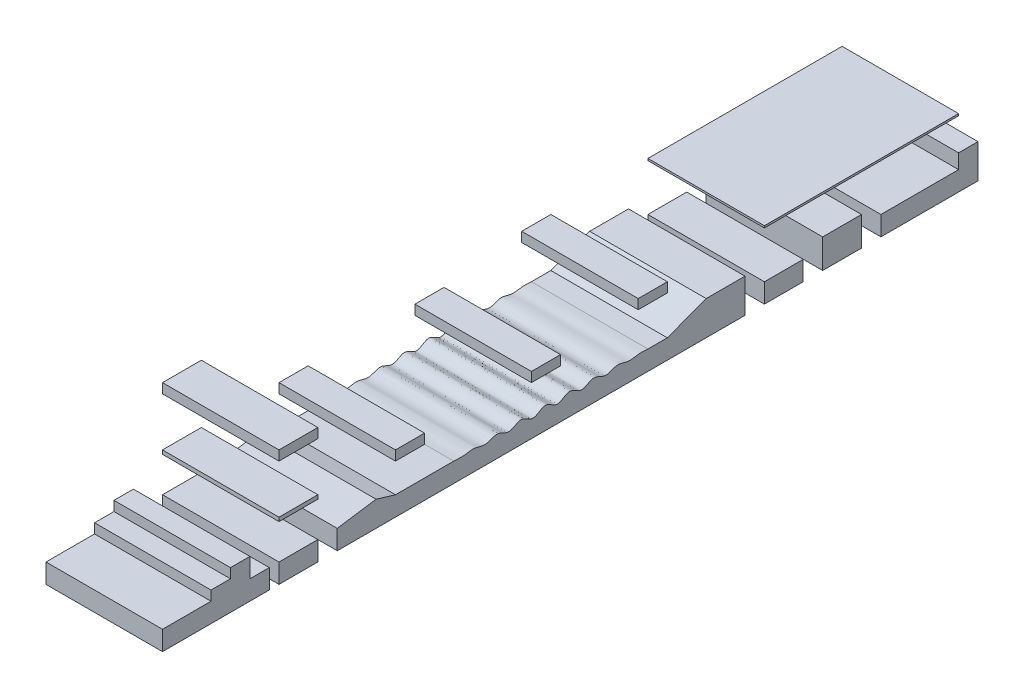
from build123d import *

# Parameters (mm, degrees)
EXTRUDE_1_DEPTH             = 3
EXTRUDE_1_2_DEPTH           = 3
SKETCH_1_W                  = 10
SKETCH_1_H                  = 0.1
EXTRUDE_1_3_DEPTH           = 3
SKETCH_1_W_2                = 2
SKETCH_1_H_2                = 1.5
EXTRUDE_1_4_DEPTH           = 3
SKETCH_1_H_3                = 1
EXTRUDE_1_5_DEPTH           = 3
SKETCH_1_W_3                = 15
EXTRUDE_1_6_DEPTH           = 3
EXTRUDE_2_DEPTH             = 3
EXTRUDE_2_DEPTH_BACK        = 3
EXTRUDE_3_DEPTH             = 3
EXTRUDE_3_DEPTH_BACK        = 3
CUT_EXTRUDE_START           = 3
SKETCH_4_W                  = 0.5
SKETCH_4_H                  = 1
SKETCH_4_W_2                = 1
CUT_EXTRUDE_1_DEPTH         = 7.0000001
EXTRUDE_4_REACH             = 5
SKETCH_5_W                  = 2
SKETCH_5_H                  = 0.2
EXTRUDE_4_DIRECTION_2_REACH = 5
EXTRUDE_5_REACH             = 5
EXTRUDE_5_DIRECTION_2_REACH = 5
EXTRUDE_START               = -3
SKETCH_7_W                  = 1.5
SKETCH_7_H                  = 0.5
EXTRUDE_6_DEPTH             = 6
EXTRUDE_6_2_DEPTH           = 6
EXTRUDE_6_3_DEPTH           = 6
SKETCH_7_W_2                = 2
EXTRUDE_6_4_DEPTH           = 6


with BuildPart() as part:
    # 草图1 → 凸台-拉伸1 (new body, symmetric)
    with BuildSketch(Plane(origin=(0, 0, 0), x_dir=(0, 0, -1), z_dir=(1, 0, 0))):
        Polygon((37, 0), (41, 0), (41, 0.75), (42, 0.75), (42, -1), (37, -1), align=None)
    extrude(amount=EXTRUDE_1_DEPTH, both=True)


with BuildPart() as body_2:
    # 草图1 → Extrude 1 2 (new body, symmetric)
    with BuildSketch(Plane(origin=(0, 0, 0), x_dir=(0, 0, -1), z_dir=(1, 0, 0))):
        Polygon((30, -1), (30, 0.75), (28, 0.75), (26, 0), (25, 0), (25, -1), align=None)
    extrude(amount=EXTRUDE_1_2_DEPTH, both=True)



with BuildPart() as body_3:
    # 草图1 → Extrude 1 3 (new body, symmetric)
    with BuildSketch(Plane(origin=(0, 0, 0), x_dir=(0, 0, -1), z_dir=(1, 0, 0))):
        with Locations((36, 2.45)):
            Rectangle(SKETCH_1_W, SKETCH_1_H)
    extrude(amount=EXTRUDE_1_3_DEPTH, both=True)


with BuildPart() as body_4:
    # 草图1 → Extrude 1 4 (new body, symmetric)
    with BuildSketch(Plane(origin=(0, 0, 0), x_dir=(0, 0, -1), z_dir=(1, 0, 0))):
        with Locations((35, -0.25)):
            Rectangle(SKETCH_1_W_2, SKETCH_1_H_2)
    extrude(amount=EXTRUDE_1_4_DEPTH, both=True)


with BuildPart() as body_5:
    # 草图1 → Extrude 1 5 (new body, symmetric)
    with BuildSketch(Plane(origin=(0, 0, 0), x_dir=(0, 0, -1), z_dir=(1, 0, 0))):
        with Locations((32, -0.5)):
            Rectangle(SKETCH_1_W_2, SKETCH_1_H_3)
    extrude(amount=EXTRUDE_1_5_DEPTH, both=True)


with BuildPart() as body_6:
    # 草图1 → Extrude 1 6 (new body, symmetric)
    with BuildSketch(Plane(origin=(0, 0, 0), x_dir=(0, 0, -1), z_dir=(1, 0, 0))):
        with Locations((7.5, -0.5)):
            Rectangle(SKETCH_1_W_3, SKETCH_1_H_3)
    extrude(amount=EXTRUDE_1_6_DEPTH, both=True)


with BuildPart() as body_2_1:
    add(body_2.part)

    add(body_6.part)  # 凸台-拉伸2 merges body 6
    # 草图2 → 凸台-拉伸2 (add, two sides)
    with BuildSketch(Plane(origin=(0, 0, 0), x_dir=(0, 0, -1), z_dir=(1, 0, 0))) as extrude_2_sk:
        with BuildLine():
            Line((25, 0), (25, -1))
            Line((25, -1), (15, -1))
            Line((15, -1), (15, 0))
            add(Edge.make_bspline(
                [(15, 0), (15.019852379, 0), (15.060190558, -0.000731178), (15.170958225, -0.004993424), (15.304514791, -0.017003842), (15.474252144, -0.021487702), (15.68874463, 0.004937048), (15.893861657, 0.051909588), (16.094951986, 0.044850487), (16.295817919, -0.009198636), (16.472538126, -0.066588084), (16.69222545, -0.079729643), (16.888335149, 0.000528924), (17.057792019, 0.071283945), (17.21996953, 0.094390627), (17.347292458, 0.072033865), (17.465227624, 0.024389734), (17.578141197, -0.031891345), (17.698483931, -0.084840948), (17.835520741, -0.113450201), (17.97049161, -0.086701778), (18.088481622, -0.029788445), (18.195304005, 0.029919779), (18.296356752, 0.08125789), (18.419356141, 0.120991981), (18.565356334, 0.111821211), (18.707223229, 0.039142021), (18.849825719, -0.049006587), (19.004553287, -0.12913704), (19.182498155, -0.125477201), (19.333914462, -0.040957938), (19.473953485, 0.048104078), (19.625939165, 0.131731177), (19.803927697, 0.130852507), (19.955368453, 0.04586001), (20.095152965, -0.044159697), (20.246692264, -0.130036088), (20.425953601, -0.13233286), (20.579865028, -0.047628059), (20.721610821, 0.042597321), (20.875124879, 0.126850879), (21.052917266, 0.126831512), (21.205681567, 0.047140906), (21.346635582, -0.039353707), (21.485341862, -0.109599979), (21.626264904, -0.120139718), (21.74489324, -0.085169656), (21.841126768, -0.038617733), (21.945725191, 0.019145441), (22.061511684, 0.07771784), (22.228121545, 0.120686636), (22.399545356, 0.071438402), (22.54263056, -0.004711258), (22.687559945, -0.064819036), (22.80938576, -0.090770941), (22.933479525, -0.081171782), (23.050482764, -0.045843176), (23.160886922, -0.001969054), (23.270309992, 0.037903038), (23.407269761, 0.0699359), (23.598735058, 0.065525517), (23.820769111, -0.018043876), (24.077234518, -0.062657182), (24.323354641, -0.012520022), (24.534895962, 0.01664141), (24.70139475, 0.017113956), (24.832869481, 0.006461173), (24.940989195, 0.001444486), (24.980546523, 0.000255205), (25, 0)],
                knots=[0.080420158, 0.080420158, 0.080420158, 0.080420158, 0.080420158, 0.08798504, 0.095549922, 0.110679687, 0.125809451, 0.140939215, 0.16517557, 0.177293748, 0.189411925, 0.207122949, 0.224833973, 0.245520981, 0.255864485, 0.266207988, 0.276282774, 0.28635756, 0.296432346, 0.306507132, 0.318373913, 0.330240694, 0.339311626, 0.348382559, 0.357453492, 0.366524424, 0.380143825, 0.393763225, 0.407382626, 0.421002027, 0.434517018, 0.448032009, 0.461547, 0.475061991, 0.488607776, 0.502153562, 0.515699347, 0.529245132, 0.542954524, 0.556663916, 0.570373307, 0.584082699, 0.597491202, 0.610899704, 0.624308207, 0.637716709, 0.646276459, 0.65483621, 0.66339596, 0.67195571, 0.684299222, 0.696642734, 0.716675493, 0.726691872, 0.736708251, 0.746449596, 0.75619094, 0.765932285, 0.77567363, 0.784483857, 0.793294084, 0.810914537, 0.835554636, 0.860194735, 0.875021766, 0.889848798, 0.904675829, 0.912089345, 0.919502861, 0.919502861, 0.919502861, 0.919502861, 0.919502861], degree=4))
        make_face()
    extrude(amount=EXTRUDE_2_DEPTH)
    extrude(extrude_2_sk.sketch, amount=-EXTRUDE_2_DEPTH_BACK)

    # 草图3 → 凸台-拉伸3 (add, two sides)
    with BuildSketch(Plane(origin=(0, 0, 0), x_dir=(0, 0, -1), z_dir=(1, 0, 0))) as extrude_3_sk:
        Polygon((2.5, 0), (2.5, 0.5), (3.5, 0.5), (3.5, 1), (4.5, 1), (4.5, 0), align=None)
    extrude(amount=EXTRUDE_3_DEPTH)
    extrude(extrude_3_sk.sketch, amount=-EXTRUDE_3_DEPTH_BACK)

    # 草图4 → 切除-拉伸1 (cut, through all)
    with BuildSketch(Plane(origin=(0, 0, 0), x_dir=(0, 0, -1), z_dir=(1, 0, 0)).offset(CUT_EXTRUDE_START)):
        with Locations((5.75, -0.5)):
            Rectangle(SKETCH_4_W, SKETCH_4_H)
        with Locations((8.5, -0.5)):
            Rectangle(SKETCH_4_W_2, SKETCH_4_H)
    extrude(amount=-CUT_EXTRUDE_1_DEPTH, mode=Mode.SUBTRACT)


with BuildPart() as body_6_2:

    # 凸台-拉伸4: up to this face of the body (flat: up to its plane)
    extrude_4_end = Plane(body_2_1.part.faces().sort_by_distance((3, -0.303571429, -2.946428571))[0])
    # 草图5 → 凸台-拉伸4 (new body, up to the picked face)
    with BuildSketch(Plane(origin=(0, 0, 0), x_dir=(0, 0, -1), z_dir=(1, 0, 0)), mode=Mode.PRIVATE) as extrude_4_sk1:
        with Locations((7, 1.9)):
            Rectangle(SKETCH_5_W, SKETCH_5_H)
    extrude_4_tool1 = split(extrude(extrude_4_sk1.sketch, amount=EXTRUDE_4_REACH, mode=Mode.PRIVATE), bisect_by=extrude_4_end, keep=Keep.BOTH, mode=Mode.PRIVATE)
    add(extrude_4_tool1.solids().sort_by_distance((0, 1.9, -7))[0])


    # 凸台-拉伸4 direction 2: up to this face of the body (flat: up to its plane)
    extrude_4_direction_2_end = Plane(body_2_1.part.faces().sort_by_distance((-3, -0.416345745, -20.388606858))[0])
    # 草图5 → 凸台-拉伸4 direction 2 (add, up to the picked face)
    with BuildSketch(Plane(origin=(0, 0, 0), x_dir=(0, 0, -1), z_dir=(1, 0, 0)), mode=Mode.PRIVATE) as extrude_4_direction_2_sk1:
        with Locations((7, 1.9)):
            Rectangle(SKETCH_5_W, SKETCH_5_H)
    extrude_4_direction_2_tool1 = split(extrude(extrude_4_direction_2_sk1.sketch, amount=-EXTRUDE_4_DIRECTION_2_REACH, mode=Mode.PRIVATE), bisect_by=extrude_4_direction_2_end, keep=Keep.BOTH, mode=Mode.PRIVATE)
    add(extrude_4_direction_2_tool1.solids().sort_by_distance((0, 1.9, -7))[0])


with BuildPart() as body_2_2:
    add(body_2_1.part)

    # 凸台-拉伸5: up to this face of the body (flat: up to its plane)
    extrude_5_end = Plane(body_2_2.part.faces().sort_by_distance((3, -0.416345745, -20.388606858))[0])
    # 草图6 → 凸台-拉伸5 (add, up to the picked face)
    with BuildSketch(Plane(origin=(0, 0, 0), x_dir=(0, 0, -1), z_dir=(1, 0, 0)), mode=Mode.PRIVATE) as extrude_5_sk1:
        Polygon((9, 0), (11, 0.3), (12, 0), align=None)
    extrude_5_tool1 = split(extrude(extrude_5_sk1.sketch, amount=EXTRUDE_5_REACH, mode=Mode.PRIVATE), bisect_by=extrude_5_end, keep=Keep.BOTH, mode=Mode.PRIVATE)
    add(extrude_5_tool1.solids().sort_by_distance((0, 0.1, -10.666667))[0])

    # 凸台-拉伸5 direction 2: up to this face of the body (flat: up to its plane)
    extrude_5_direction_2_end = Plane(body_2_2.part.faces().sort_by_distance((-3, -0.416345745, -20.388606858))[0])
    # 草图6 → 凸台-拉伸5 direction 2 (add, up to the picked face)
    with BuildSketch(Plane(origin=(0, 0, 0), x_dir=(0, 0, -1), z_dir=(1, 0, 0)), mode=Mode.PRIVATE) as extrude_5_direction_2_sk1:
        Polygon((9, 0), (11, 0.3), (12, 0), align=None)
    extrude_5_direction_2_tool1 = split(extrude(extrude_5_direction_2_sk1.sketch, amount=-EXTRUDE_5_DIRECTION_2_REACH, mode=Mode.PRIVATE), bisect_by=extrude_5_direction_2_end, keep=Keep.BOTH, mode=Mode.PRIVATE)
    add(extrude_5_direction_2_tool1.solids().sort_by_distance((0, 0.1, -10.666667))[0])


with BuildPart() as body_7:
    # 草图7 → 凸台-拉伸6 (new body)
    with BuildSketch(Plane(origin=(0, 0, 0), x_dir=(0, 0, -1), z_dir=(1, 0, 0)).offset(EXTRUDE_START)):
        with Locations((12.75, 1.75)):
            Rectangle(SKETCH_7_W, SKETCH_7_H)
    extrude(amount=EXTRUDE_6_DEPTH)


with BuildPart() as body_8:
    # 草图7 → Extrude 6 2 (new body)
    with BuildSketch(Plane(origin=(0, 0, 0), x_dir=(0, 0, -1), z_dir=(1, 0, 0)).offset(EXTRUDE_START)):
        with Locations((25.25, 2.25)):
            Rectangle(SKETCH_7_W, SKETCH_7_H)
    extrude(amount=EXTRUDE_6_2_DEPTH)


with BuildPart() as body_9:
    # 草图7 → Extrude 6 3 (new body)
    with BuildSketch(Plane(origin=(0, 0, 0), x_dir=(0, 0, -1), z_dir=(1, 0, 0)).offset(EXTRUDE_START)):
        with Locations((19.75, 1.75)):
            Rectangle(SKETCH_7_W, SKETCH_7_H)
    extrude(amount=EXTRUDE_6_3_DEPTH)


with BuildPart() as body_10:
    # 草图7 → Extrude 6 4 (new body)
    with BuildSketch(Plane(origin=(0, 0, 0), x_dir=(0, 0, -1), z_dir=(1, 0, 0)).offset(EXTRUDE_START)):
        with Locations((7, 4.75)):
            Rectangle(SKETCH_7_W_2, SKETCH_7_H)
    extrude(amount=EXTRUDE_6_4_DEPTH)


solid = Compound([part.part, body_3.part, body_4.part, body_5.part, body_6_2.part, body_2_2.part, body_7.part, body_8.part, body_9.part, body_10.part])
